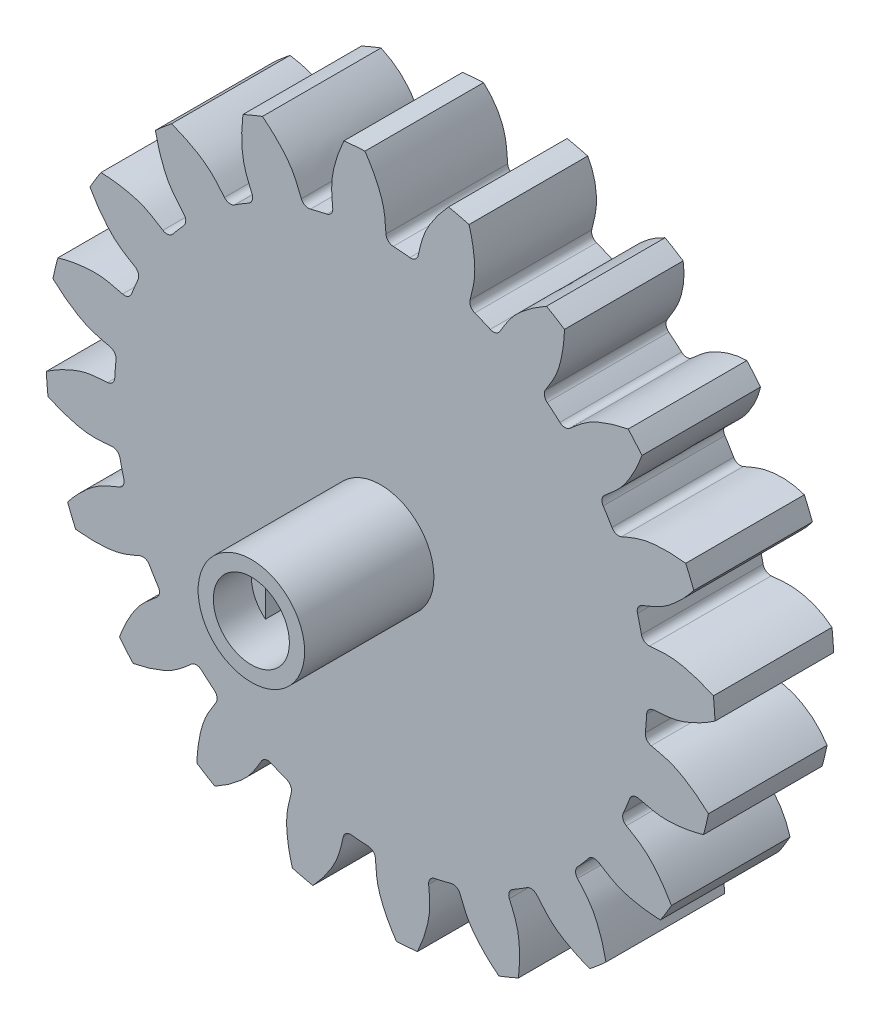
from build123d import *

# Parameters (mm, degrees)
SKETCH4_R                = 17.5
BOSS_EXTRUDE2_DEPTH      = 10
BOSS_EXTRUDE3_DEPTH      = 10
FILLET1_R                = 0.5
CIRPATTERN1_COUNT        = 20
FILLET1_OF_CIRPATTERN1_R = 0.5
SKETCH8_R                = 25
CUT_EXTRUDE2_DEPTH       = 2
SKETCH9_R                = 3.5
BOSS_EXTRUDE4_DEPTH      = 8.5
CUT_EXTRUDE3_DEPTH       = 8.5
SKETCH11_R               = 2.5
CUT_EXTRUDE4_DEPTH       = 2.5


with BuildPart() as part:
    # Sketch4 → Boss-Extrude2 (new body)
    with BuildSketch(Plane.XY):
        Circle(SKETCH4_R)
    extrude(amount=BOSS_EXTRUDE2_DEPTH)

    # Sketch3 → Boss-Extrude3 (add)
    with BuildSketch(Plane.XY):
        with BuildLine():
            ThreePointArc((-1.03267312, 21.975749958), (-1.726100106, 21.932181342), (-2.417805488, 21.866737677))
            add(Edge.make_bspline(
                [(-3.114339189, 17.220653049), (-3.160079247, 17.912144851), (-3.298659823, 18.775292328), (-3.127363068, 19.784781367), (-3.009171352, 20.29468964), (-2.788912463, 21.006938533), (-2.572369364, 21.53562073), (-2.417805488, 21.866737677)],
                knots=[0, 0, 0, 0, 0.441913338, 0.532273099, 0.641803294, 0.770503925, 1, 1, 1, 1], degree=3))
            ThreePointArc((-3.114339189, 17.220653049), (-1.373034175, 17.44605334), (0.382092858, 17.495828218))
            add(Edge.make_bspline(
                [(0.382092858, 17.495828218), (0.31909663, 18.18596193), (0.320945035, 19.060161408), (-0.00616165, 20.030425246), (-0.202665458, 20.515566444), (-0.531632869, 21.18459029), (-0.82821408, 21.672888728), (-1.03267312, 21.975749958)],
                knots=[0, 0, 0, 0, 0.441913338, 0.532273099, 0.641803294, 0.770503925, 1, 1, 1, 1], degree=3))
        make_face()
    boss_extrude3 = extrude(amount=BOSS_EXTRUDE3_DEPTH)

    # Fillet1
    fillet1_edges = [part.edges().sort_by_distance(p)[0] for p in [
        (0.382092858, 17.495828218, 5),
        (-3.114339189, 17.220653049, 5),
    ]]
    fillet(fillet1_edges, radius=FILLET1_R)

    # CirPattern1: Boss-Extrude3 ×20 about axis
    cirpattern1_axis = Axis((0, 0, -86.49), (0, 0, 1))
    for i in range(1, CIRPATTERN1_COUNT):
        add(boss_extrude3.rotate(cirpattern1_axis, i * 360 / CIRPATTERN1_COUNT))

    # Fillet1 of CirPattern1
    fillet1_of_cirpattern1_edges = [part.edges().sort_by_distance(p)[0] for p in [
        (-5.043116348, 16.757594622, 5),
        (-8.283387026, 15.415430561, 5),
        (-9.974670188, 14.379010906, 5),
        (-12.641599227, 12.101238325, 5),
        (-13.929833812, 10.592909419, 5),
        (-15.762363616, 7.602492567, 5),
        (-16.521448249, 5.769900153, 5),
        (-17.340198032, 2.359561867, 5),
        (-17.495828218, 0.382092858, 5),
        (-17.220653049, -3.114339189, 5),
        (-16.757594622, -5.043116348, 5),
        (-15.415430561, -8.283387026, 5),
        (-14.379010906, -9.974670188, 5),
        (-12.101238325, -12.641599227, 5),
        (-10.592909419, -13.929833812, 5),
        (-7.602492567, -15.762363616, 5),
        (-5.769900153, -16.521448249, 5),
        (-2.359561867, -17.340198032, 5),
        (-0.382092858, -17.495828218, 5),
        (3.114339189, -17.220653049, 5),
        (5.043116348, -16.757594622, 5),
        (8.283387026, -15.415430561, 5),
        (9.974670188, -14.379010906, 5),
        (12.641599227, -12.101238325, 5),
        (13.929833812, -10.592909419, 5),
        (15.762363616, -7.602492567, 5),
        (16.521448249, -5.769900153, 5),
        (17.340198032, -2.359561867, 5),
        (17.495828218, -0.382092858, 5),
        (17.220653049, 3.114339189, 5),
        (16.757594622, 5.043116348, 5),
        (15.415430561, 8.283387026, 5),
        (14.379010906, 9.974670188, 5),
        (12.101238325, 12.641599227, 5),
        (10.592909419, 13.929833812, 5),
        (7.602492567, 15.762363616, 5),
        (5.769900153, 16.521448249, 5),
        (2.359561867, 17.340198032, 5),
    ]]
    fillet(fillet1_of_cirpattern1_edges, radius=FILLET1_OF_CIRPATTERN1_R)

    # Sketch7 → Cut-Revolve2 (revolve, cut)
    with BuildSketch(Plane(origin=(0, 0, 0), x_dir=(1, 0, 0), z_dir=(0, 1, 0))):
        with BuildLine():
            Line((-18, 0), (-20, 0))
            ThreePointArc((-20, 0), (-22.043096437, -0.210936871), (-24, -0.83484861))
            Line((-24, -0.83484861), (-24, 2))
            Line((-24, 2), (-18, 2))
            Line((-18, 2), (-18, 0))
        make_face()
    revolve(axis=Axis((0, 0, -6.148940333), (0, 0, 1)), mode=Mode.SUBTRACT)

    # Sketch8 → Cut-Extrude2 (cut)
    with BuildSketch(Plane.XY.offset(10)):
        Circle(SKETCH8_R)
    extrude(amount=-CUT_EXTRUDE2_DEPTH, mode=Mode.SUBTRACT)

    # Sketch9 → Boss-Extrude4 (add)
    with BuildSketch(Plane.XY.offset(8)):
        Circle(SKETCH9_R)
    extrude(amount=BOSS_EXTRUDE4_DEPTH)

    # Sketch10 → Cut-Extrude3 (cut)
    with BuildSketch(Plane.XY.offset(16.5)):
        with BuildLine():
            Line((-1.575, 1.941487832), (-1.575, -1.941487832))
            ThreePointArc((-1.575, -1.941487832), (0, -2.5), (1.575, -1.941487832))
            Line((1.575, -1.941487832), (1.575, 1.941487832))
            ThreePointArc((1.575, 1.941487832), (0, 2.5), (-1.575, 1.941487832))
        make_face()
    extrude(amount=-CUT_EXTRUDE3_DEPTH, mode=Mode.SUBTRACT)

    # Sketch11 → Cut-Extrude4 (cut)
    with BuildSketch(Plane.XY.offset(16.5)):
        Circle(SKETCH11_R)
    extrude(amount=-CUT_EXTRUDE4_DEPTH, mode=Mode.SUBTRACT)


solid = part.part
